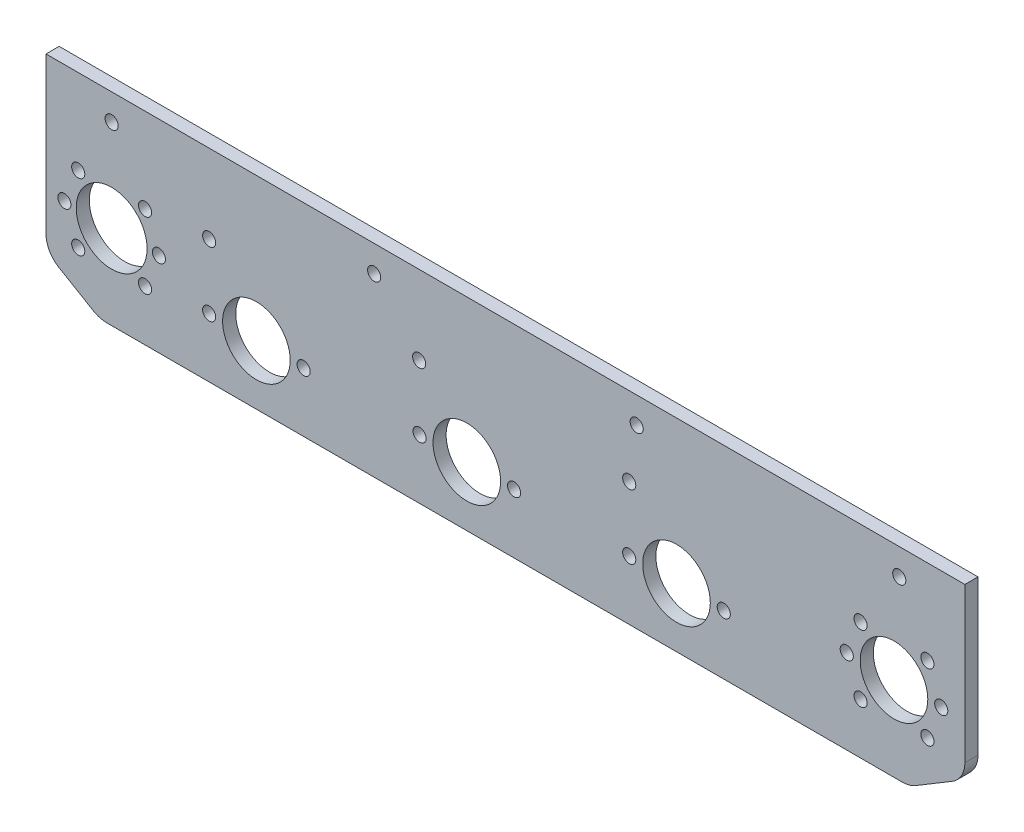
from build123d import *

# Parameters (mm, degrees)
SKETCH_1_R      = 2.5
SKETCH_1_R_2    = 12.875
SKETCH_1_R_3    = 13.5
EXTRUDE_1_DEPTH = 5


with BuildPart() as part:
    # 草圖1 → 填料-伸長1 (new body)
    with BuildSketch(Plane.XY):
        with BuildLine():
            Line((-174, 57.428011653), (176, 57.428011653))
            Line((176, 57.428011653), (176, 7.612503487))
            Line((176, 7.612503487), (176, -1.381476285))
            ThreePointArc((176, -1.381476285), (174.702583739, -6.307431651), (171.146992746, -9.955184098))
            Line((171.146992746, -9.955184098), (157.274783453, -18.282988376))
            ThreePointArc((157.274783453, -18.282988376), (154.798270239, -19.346112982), (152.127790707, -19.709280563))
            Line((152.127790707, -19.709280563), (-150.840267353, -19.709280563))
            ThreePointArc((-150.840267353, -19.709280563), (-153.474646249, -19.356044157), (-155.922913438, -18.32129013))
            Line((-155.922913438, -18.32129013), (-169.082646085, -10.55466341))
            ThreePointArc((-169.082646085, -10.55466341), (-172.684079135, -6.901158615), (-174, -1.942653843))
            Line((-174, -1.942653843), (-174, 0.523128234))
            Line((-174, 0.523128234), (-174, 7.612503487))
            Line((-174, 7.612503487), (-174, 57.428011653))
        make_face()
        with Locations((131, 12.428011653)):
            Circle(SKETCH_1_R, mode=Mode.SUBTRACT)
        with Locations((167, 12.428011653)):
            Circle(SKETCH_1_R, mode=Mode.SUBTRACT)
        with Locations((149, 12.428011653)):
            Circle(SKETCH_1_R_2, mode=Mode.SUBTRACT)
        with Locations((-149, 12.428011653)):
            Circle(SKETCH_1_R_3, mode=Mode.SUBTRACT)
        with Locations((-136.272077939, 25.155933714)):
            Circle(SKETCH_1_R, mode=Mode.SUBTRACT)
        with Locations((-161.727922061, 25.155933714)):
            Circle(SKETCH_1_R, mode=Mode.SUBTRACT)
        with Locations((-136.272077939, -0.299910409)):
            Circle(SKETCH_1_R, mode=Mode.SUBTRACT)
        with Locations((-161.727922061, -0.299910409)):
            Circle(SKETCH_1_R, mode=Mode.SUBTRACT)
        with Locations((-111.854812337, 27.428011653)):
            Circle(SKETCH_1_R, mode=Mode.SUBTRACT)
        with Locations((-31.854812337, 27.428011653)):
            Circle(SKETCH_1_R, mode=Mode.SUBTRACT)
        with Locations((48.145187663, 27.428011653)):
            Circle(SKETCH_1_R, mode=Mode.SUBTRACT)
        with Locations((-93.857391311, 2.88519493)):
            Circle(SKETCH_1_R_2, mode=Mode.SUBTRACT)
        with Locations((-75.857391311, 2.88519493)):
            Circle(SKETCH_1_R, mode=Mode.SUBTRACT)
        with Locations((-111.857391311, 2.88519493)):
            Circle(SKETCH_1_R, mode=Mode.SUBTRACT)
        with Locations((-31.716358152, 2.955487842)):
            Circle(SKETCH_1_R, mode=Mode.SUBTRACT)
        with Locations((-13.716358152, 2.955487842)):
            Circle(SKETCH_1_R_2, mode=Mode.SUBTRACT)
        with Locations((4.283641848, 2.955487842)):
            Circle(SKETCH_1_R, mode=Mode.SUBTRACT)
        with Locations((48.158653697, 2.877678962)):
            Circle(SKETCH_1_R, mode=Mode.SUBTRACT)
        with Locations((66.158653697, 2.877678962)):
            Circle(SKETCH_1_R_2, mode=Mode.SUBTRACT)
        with Locations((84.158653697, 2.877678962)):
            Circle(SKETCH_1_R, mode=Mode.SUBTRACT)
        with Locations((-149, 47.428011653)):
            Circle(SKETCH_1_R, mode=Mode.SUBTRACT)
        with Locations((-49, 47.428011653)):
            Circle(SKETCH_1_R, mode=Mode.SUBTRACT)
        with Locations((51, 47.428011653)):
            Circle(SKETCH_1_R, mode=Mode.SUBTRACT)
        with Locations((151, 47.428011653)):
            Circle(SKETCH_1_R, mode=Mode.SUBTRACT)
        with Locations((-167, 12.428011653)):
            Circle(SKETCH_1_R, mode=Mode.SUBTRACT)
        with Locations((-131, 12.428011653)):
            Circle(SKETCH_1_R, mode=Mode.SUBTRACT)
        with Locations((161.727922061, -0.299910409)):
            Circle(SKETCH_1_R, mode=Mode.SUBTRACT)
        with Locations((136.272077939, -0.299910409)):
            Circle(SKETCH_1_R, mode=Mode.SUBTRACT)
        with Locations((136.272077939, 25.155933714)):
            Circle(SKETCH_1_R, mode=Mode.SUBTRACT)
        with Locations((161.727922061, 25.155933714)):
            Circle(SKETCH_1_R, mode=Mode.SUBTRACT)
    extrude(amount=EXTRUDE_1_DEPTH)


solid = part.part
